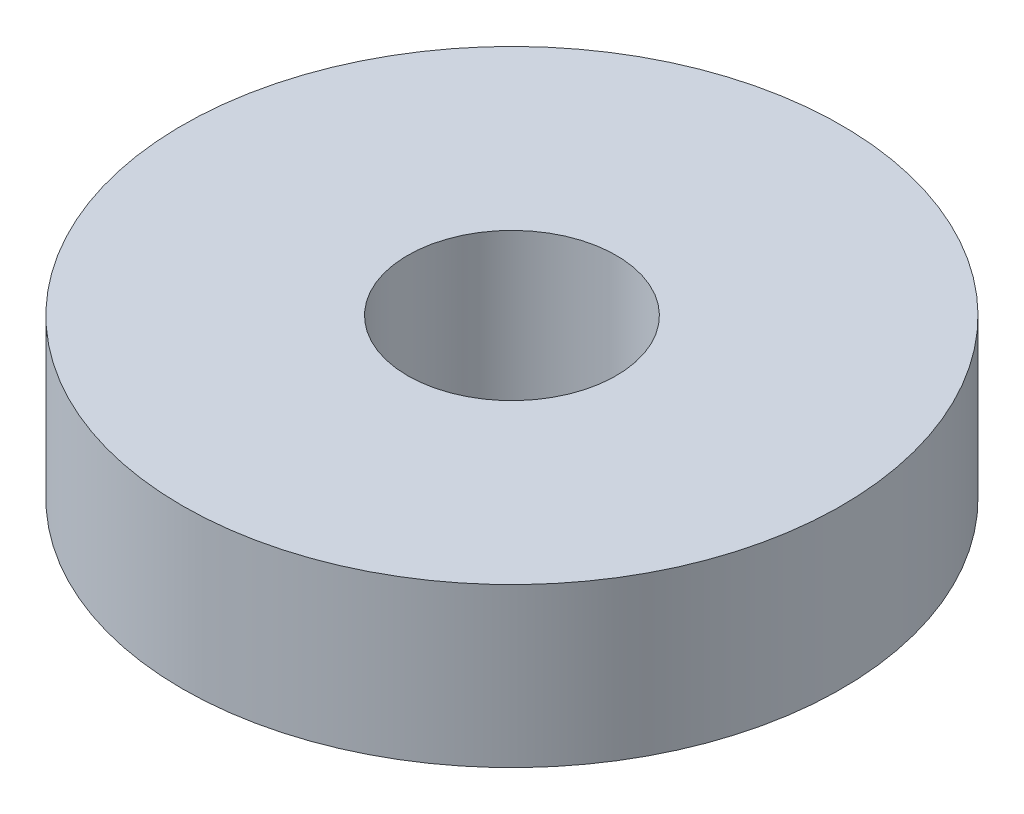
from build123d import *

# Parameters (mm, degrees)
SKETCH1_R           = 3.95
SKETCH1_R_2         = 1.25
BOSS_EXTRUDE1_DEPTH = 1.9


with BuildPart() as part:
    # Sketch1 → Boss-Extrude1 (new body)
    with BuildSketch(Plane(origin=(0, 0, 0), x_dir=(1, 0, 0), z_dir=(0, 1, 0))):
        Circle(SKETCH1_R)
        Circle(SKETCH1_R_2, mode=Mode.SUBTRACT)
    extrude(amount=BOSS_EXTRUDE1_DEPTH)


solid = part.part
